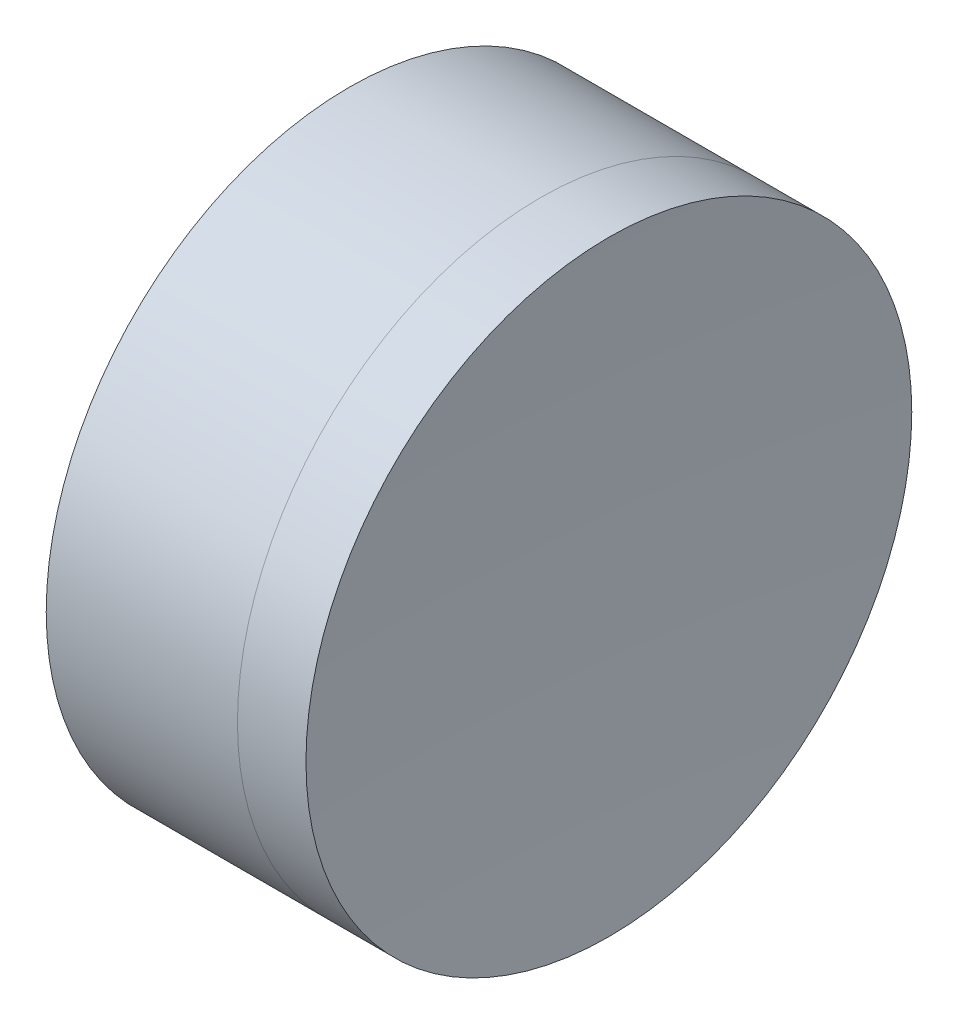
from build123d import *


with BuildPart() as part:
    # 草图1 one side → 旋转1 (revolve)
    with BuildSketch(Plane(origin=(0, 0, 0), x_dir=(1, 0, 0), z_dir=(0, 1, 0)), mode=Mode.PRIVATE) as revolve_1_sk:
        with BuildLine():
            Line((232.082353021, 6.35), (228.073176118, 6.35))
            ThreePointArc((228.073176118, 6.35), (228.999044601, 3.234810403), (229.311519118, 0))
            Line((229.311519118, 0), (230.811519118, 0))
            ThreePointArc((230.811519118, 0), (231.132346695, 3.237959188), (232.082353021, 6.35))
        make_face()
    revolve(revolve_1_sk.sketch.rotate(Axis((-0.816062176, 0, 0), (1, 0, 0)), 180), axis=Axis((-0.816062176, 0, 0), (1, 0, 0)))  # turned: the seam where the file's is


with BuildPart() as body_2:
    # 草图2 one side → 旋转3 (revolve)
    with BuildSketch(Plane(origin=(0, 0, 0), x_dir=(1, 0, 0), z_dir=(0, 1, 0)), mode=Mode.PRIVATE) as revolve_3_sk:
        with BuildLine():
            Line((233.518096263, 6.35), (232.082353021, 6.35))
            ThreePointArc((232.082353021, 6.35), (231.132346695, 3.237959188), (230.811519118, 0))
            Line((230.811519118, 0), (233.311519118, 0))
            ThreePointArc((233.311519118, 0), (233.363177061, 3.176679639), (233.518096263, 6.35))
        make_face()
    revolve(revolve_3_sk.sketch.rotate(Axis((228.073176118, 0, 0), (1, 0, 0)), 180), axis=Axis((228.073176118, 0, 0), (1, 0, 0)))  # turned: the seam where the file's is


solid = Compound([part.part, body_2.part])
